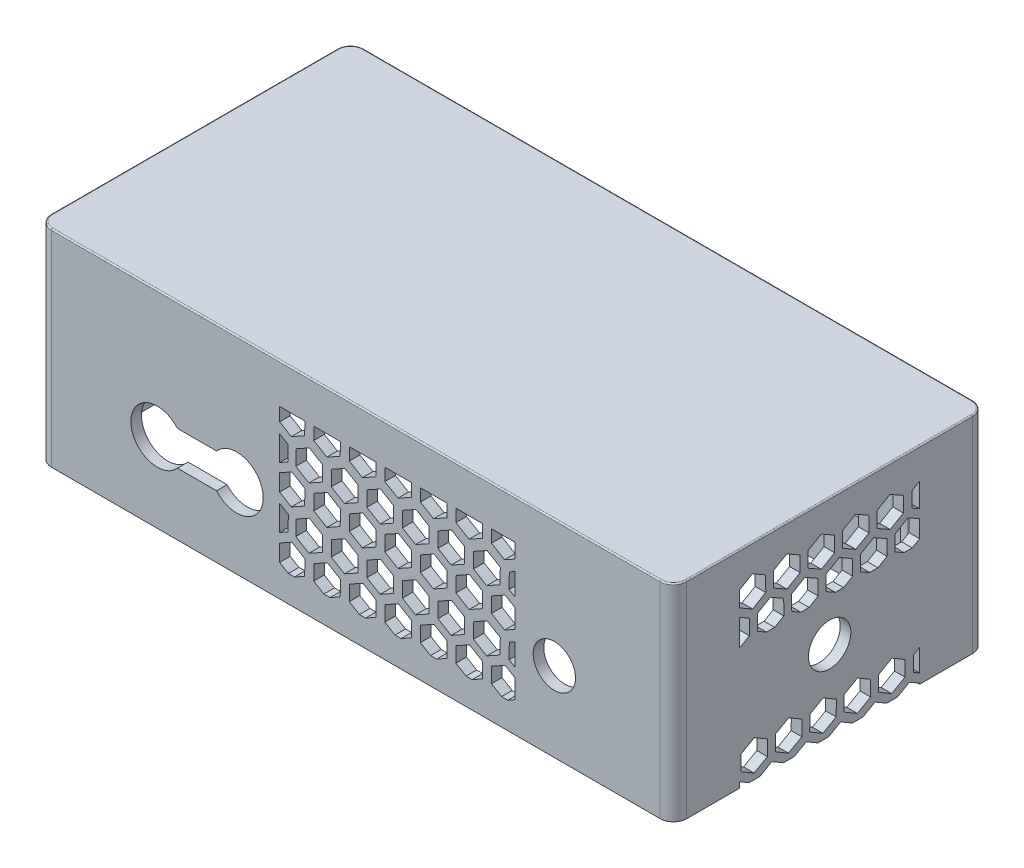
from build123d import *

# Parameters (mm, degrees)
SKETCH1_W                             = 240
SKETCH1_H                             = 118
BOSS_EXTRUDE1_DEPTH                   = 78
SKETCH2_W                             = 232
SKETCH2_H                             = 110
CUT_EXTRUDE1_DEPTH                    = 70
SKETCH3_W                             = 14
SKETCH3_H                             = 22
BOSS_EXTRUDE2_DEPTH                   = 77.2
FILLET1_R                             = 2
FILLET2_R                             = 6.5
FILLET3_R                             = 5
SKETCH4_R                             = 8
SIDE_LIDAR_AND_SONAR_HOLES_DEPTH      = 60
SIDE_LIDAR_AND_SONAR_HOLES_DEPTH_BACK = 60
SIDE_HONEYCOMB_DEPTH                  = 60
SIDE_HONEYCOMB_DEPTH_BACK             = 60
SKETCH6_R                             = 8
BACK_SONAR_DEPTH                      = 145
BACK_HONEYCOMB_DEPTH                  = 121
FILLET4_R                             = 0.5
FILLET6_R                             = 0.5


with BuildPart() as part:
    # Sketch1 → Boss-Extrude1 (new body)
    with BuildSketch(Plane(origin=(0, 0, 0), x_dir=(1, 0, 0), z_dir=(0, 1, 0))):
        Rectangle(SKETCH1_W, SKETCH1_H)
    extrude(amount=BOSS_EXTRUDE1_DEPTH)

    # Sketch2 → Cut-Extrude1 (cut)
    with BuildSketch(Plane(origin=(0, 0, 0), x_dir=(1, 0, 0), z_dir=(0, 1, 0))):
        Rectangle(SKETCH2_W, SKETCH2_H)
    extrude(amount=CUT_EXTRUDE1_DEPTH, mode=Mode.SUBTRACT)

    # Sketch3 → Boss-Extrude2 (add)
    with BuildSketch(Plane(origin=(0, 0, 0), x_dir=(1, 0, 0), z_dir=(0, 1, 0))):
        with Locations((-113, -48)):
            Rectangle(SKETCH3_W, SKETCH3_H)
        with Locations((-113, 48)):
            Rectangle(SKETCH3_W, SKETCH3_H)
        with Locations((113, -48)):
            Rectangle(SKETCH3_W, SKETCH3_H)
        with Locations((113, 48)):
            Rectangle(SKETCH3_W, SKETCH3_H)
    extrude(amount=BOSS_EXTRUDE2_DEPTH)

    # Fillet1
    fillet1_edges = [part.edges().sort_by_distance(p)[0] for p in [
        (-106, 35, 55),
        (-116, 35, 37),
        (-106, 35, -55),
        (-116, 35, -37),
        (116, 35, 37),
        (106, 35, 55),
        (116, 35, -37),
        (106, 35, -55),
    ]]
    fillet(fillet1_edges, radius=FILLET1_R)

    # Fillet2
    fillet2_edges = [part.edges().sort_by_distance(p)[0] for p in [
        (-106, 35, 37),
        (-106, 35, -37),
        (106, 35, 37),
        (106, 35, -37),
    ]]
    fillet(fillet2_edges, radius=FILLET2_R)

    # Fillet3
    fillet3_edges = [part.edges().sort_by_distance(p)[0] for p in [
        (-120, 39, -59),
        (120, 39, -59),
        (120, 39, 59),
        (-120, 39, 59),
    ]]
    fillet(fillet3_edges, radius=FILLET3_R)

    # Sketch4 → Side Lidar and Sonar holes (cut, two sides)
    with BuildSketch(Plane.XY) as side_lidar_and_sonar_holes_sk:
        with Locations((75, 30)):
            Circle(SKETCH4_R)
        with BuildLine():
            Line((-67.400657923, 23.5), (-52.599342077, 23.5))
            ThreePointArc((-52.599342077, 23.5), (-35, 30), (-52.599342077, 36.5))
            Line((-52.599342077, 36.5), (-67.400657923, 36.5))
            ThreePointArc((-67.400657923, 36.5), (-85, 30), (-67.400657923, 23.5))
        make_face()
    extrude(amount=SIDE_LIDAR_AND_SONAR_HOLES_DEPTH, mode=Mode.SUBTRACT)
    extrude(side_lidar_and_sonar_holes_sk.sketch, amount=-SIDE_LIDAR_AND_SONAR_HOLES_DEPTH_BACK, mode=Mode.SUBTRACT)

    # Sketch5 → Side honeycomb (cut, two sides)
    with BuildSketch(Plane.XY) as side_honeycomb_sk:
        Polygon((-19.337989227, 12.135440218), (-19.242729189, 17.908156984), (-24.194418539, 20.87701298), (-28.788182312, 18.324921994), (-28.788182312, 11.971607029), (-25.499782491, 10), (-23.18178162, 10), align=None)
        Polygon((-17.715816895, 20.490573702), (-12.668867508, 23.294434472), (-12.57360747, 29.067151238), (-17.552209114, 32.052142884), (-22.599158501, 29.248282113), (-22.694418539, 23.475565347), align=None)
        Polygon((-28.788182312, 41.324921994), (-28.788182312, 34.971607028), (-24.384938614, 32.331579448), (-19.337989227, 35.135440218), (-19.242729189, 40.908156984), (-24.194418539, 43.87701298), align=None)
        Polygon((-17.715816895, 43.490573702), (-12.668867508, 46.294434472), (-12.57360747, 52.067151238), (-17.552209114, 55.052142884), (-22.599158501, 52.248282113), (-22.694418539, 46.475565347), align=None)
        Polygon((-28.788182312, 63), (-28.788182312, 57.971607028), (-24.384938614, 55.331579448), (-19.337989227, 58.135440218), (-19.257715386, 63), align=None)
        Polygon((-5.827715386, 63), (-15.829076835, 63), (-15.906627963, 58.300435443), (-10.954938614, 55.331579448), (-5.907989227, 58.135440218), align=None)
        Polygon((7.602284614, 63), (-2.399076835, 63), (-2.476627963, 58.300435443), (2.475061386, 55.331579448), (7.522010773, 58.135440218), align=None)
        Polygon((-4.285816895, 43.490573702), (0.761132492, 46.294434472), (0.85639253, 52.067151238), (-4.122209114, 55.052142884), (-9.169158501, 52.248282113), (-9.264418539, 46.475565347), align=None)
        Polygon((2.475061386, 32.331579448), (7.522010773, 35.135440218), (7.617270811, 40.908156984), (2.665581461, 43.87701298), (-2.381367925, 41.073152209), (-2.476627963, 35.300435443), align=None)
        Polygon((-10.954938614, 32.331579448), (-5.907989227, 35.135440218), (-5.812729189, 40.908156984), (-10.764418539, 43.87701298), (-15.811367925, 41.073152209), (-15.906627963, 35.300435443), align=None)
        Polygon((-15.906627963, 12.300435443), (-12.069782491, 10), (-9.75178162, 10), (-5.907989227, 12.135440218), (-5.812729189, 17.908156984), (-10.764418539, 20.87701298), (-15.811367925, 18.073152209), align=None)
        Polygon((-2.476627963, 12.300435443), (1.360217509, 10), (3.67821838, 10), (7.522010773, 12.135440218), (7.617270811, 17.908156984), (2.665581461, 20.87701298), (-2.381367925, 18.073152209), align=None)
        Polygon((9.144183105, 20.490573702), (14.191132492, 23.294434472), (14.28639253, 29.067151238), (9.307790886, 32.052142884), (4.260841499, 29.248282113), (4.165581461, 23.475565347), align=None)
        Polygon((15.905061386, 32.331579448), (20.952010773, 35.135440218), (21.047270811, 40.908156984), (16.095581461, 43.87701298), (11.048632075, 41.073152209), (10.953372037, 35.300435443), align=None)
        Polygon((9.144183105, 43.490573702), (14.191132492, 46.294434472), (14.28639253, 52.067151238), (9.307790886, 55.052142884), (4.260841499, 52.248282113), (4.165581461, 46.475565347), align=None)
        Polygon((21.032284614, 63), (11.030923165, 63), (10.953372037, 58.300435443), (15.905061386, 55.331579448), (20.952010773, 58.135440218), align=None)
        Polygon((22.574183105, 43.490573702), (27.621132492, 46.294434472), (27.71639253, 52.067151238), (22.737790886, 55.052142884), (17.690841499, 52.248282113), (17.595581461, 46.475565347), align=None)
        Polygon((29.335061386, 32.331579448), (34.382010773, 35.135440218), (34.477270811, 40.908156984), (29.525581461, 43.87701298), (24.478632075, 41.073152209), (24.383372037, 35.300435443), align=None)
        Polygon((22.574183105, 20.490573702), (27.621132492, 23.294434472), (27.71639253, 29.067151238), (22.737790886, 32.052142884), (17.690841499, 29.248282113), (17.595581461, 23.475565347), align=None)
        Polygon((10.953372037, 12.300435443), (14.790217509, 10), (17.10821838, 10), (20.952010773, 12.135440218), (21.047270811, 17.908156984), (16.095581461, 20.87701298), (11.048632075, 18.073152209), align=None)
        Polygon((24.383372037, 12.300435443), (28.220217509, 10), (30.53821838, 10), (34.382010773, 12.135440218), (34.477270811, 17.908156984), (29.525581461, 20.87701298), (24.478632075, 18.073152209), align=None)
        Polygon((36.004183105, 20.490573702), (41.051132492, 23.294434472), (41.14639253, 29.067151238), (36.167790886, 32.052142884), (31.120841499, 29.248282113), (31.025581461, 23.475565347), align=None)
        Polygon((42.765061386, 32.331579448), (47.812010773, 35.135440218), (47.907270811, 40.908156984), (42.955581461, 43.87701298), (37.908632075, 41.073152209), (37.813372037, 35.300435443), align=None)
        Polygon((36.004183105, 43.490573702), (41.051132492, 46.294434472), (41.14639253, 52.067151238), (36.167790886, 55.052142884), (31.120841499, 52.248282113), (31.025581461, 46.475565347), align=None)
        Polygon((34.462284614, 63), (24.460923165, 63), (24.383372037, 58.300435443), (29.335061386, 55.331579448), (34.382010773, 58.135440218), align=None)
        Polygon((47.892284614, 63), (37.890923165, 63), (37.813372037, 58.300435443), (42.765061386, 55.331579448), (47.812010773, 58.135440218), align=None)
        Polygon((60.051433795, 63), (51.320923165, 63), (51.243372037, 58.300435443), (56.195061386, 55.331579448), (60.051433795, 57.474008564), align=None)
        Polygon((49.434183105, 43.490573702), (54.481132492, 46.294434472), (54.57639253, 52.067151238), (49.597790886, 55.052142884), (44.550841499, 52.248282113), (44.455581461, 46.475565347), align=None)
        Polygon((56.195061386, 32.331579448), (60.051433795, 34.474008564), (60.051433795, 41.679098912), (56.385581461, 43.87701298), (51.338632075, 41.073152209), (51.243372037, 35.300435443), align=None)
        Polygon((49.434183105, 20.490573702), (54.481132492, 23.294434472), (54.57639253, 29.067151238), (49.597790886, 32.052142884), (44.550841499, 29.248282113), (44.455581461, 23.475565347), align=None)
        Polygon((37.813372037, 12.300435443), (41.650217509, 10), (43.96821838, 10), (47.812010773, 12.135440218), (47.907270811, 17.908156984), (42.955581461, 20.87701298), (37.908632075, 18.073152209), align=None)
        Polygon((51.243372037, 12.300435443), (55.080217509, 10), (57.39821838, 10), (60.051433795, 11.474008564), (60.051433795, 18.679098912), (56.385581461, 20.87701298), (51.338632075, 18.073152209), align=None)
        Polygon((57.885581461, 23.475565347), (60.051433795, 22.17699768), (60.051433795, 30.398611166), (57.980841499, 29.248282113), align=None)
        Polygon((57.885581461, 46.475565347), (60.051433795, 45.17699768), (60.051433795, 53.398611166), (57.980841499, 52.248282113), align=None)
        Polygon((-28.788182312, 54.043770605), (-28.788182312, 44.656019005), (-25.708051359, 46.367202868), (-25.612791321, 52.139919633), align=None)
        Polygon((-28.788182312, 31.290347439), (-28.788182312, 21.777080674), (-25.599391493, 23.548631129), (-25.504131456, 29.321347894), align=None)
        Polygon((-9.169158501, 29.248282113), (-9.264418539, 23.475565347), (-4.285816895, 20.490573702), (0.761132492, 23.294434472), (0.85639253, 29.067151238), (-4.122209114, 32.052142884), align=None)
    extrude(amount=SIDE_HONEYCOMB_DEPTH, mode=Mode.SUBTRACT)
    extrude(side_honeycomb_sk.sketch, amount=-SIDE_HONEYCOMB_DEPTH_BACK, mode=Mode.SUBTRACT)

    # Sketch6 → Back Sonar (cut)
    with BuildSketch(Plane(origin=(0, 0, 0), x_dir=(0, 0, -1), z_dir=(1, 0, 0))):
        with Locations((0, 30)):
            Circle(SKETCH6_R)
    extrude(amount=BACK_SONAR_DEPTH, mode=Mode.SUBTRACT)

    # Sketch7 → Back Honeycomb (cut, through all)
    with BuildSketch(Plane(origin=(0, 0, 0), x_dir=(0, 0, -1), z_dir=(1, 0, 0))):
        Polygon((24.693001966, 47.965061299), (28.141421751, 46), (31.23665938, 46), (33.999999792, 47.616293449), (33.999999792, 54.171182077), (29.644009316, 56.653417082), (24.660393366, 53.738471904), align=None)
        Polygon((31.182214843, 59.044689386), (33.999999792, 57.433176236), (33.999999792, 66.474168555), (31.158592725, 64.818143874), align=None)
        Polygon((22.824808943, 67.725285503), (17.841192996, 64.810340327), (17.873800031, 59.036928806), (22.890024636, 56.178463348), (27.873640641, 59.093408559), (27.841033493, 64.866820077), align=None)
        Polygon((11.693002499, 47.965061299), (15.141422283, 46), (18.236659913, 46), (21.692844087, 48.021541687), (21.660235501, 53.794951028), (16.644009849, 56.653417082), (11.660393899, 53.738471904), align=None)
        Polygon((-1.306996968, 47.965061299), (2.141422816, 46), (5.236660446, 46), (8.692844222, 48.021541454), (8.660235631, 53.794951257), (3.644010382, 56.653417082), (-1.339605568, 53.738471904), align=None)
        Polygon((9.824809476, 67.725285503), (4.841193529, 64.810340327), (4.873800563, 59.036928806), (9.890025169, 56.178463348), (14.873641174, 59.093408559), (14.841034026, 64.866820077), align=None)
        Polygon((-3.175189991, 67.725285503), (-8.158805938, 64.810340327), (-8.126198904, 59.036928806), (-3.109974298, 56.178463348), (1.873641706, 59.093408559), (1.841034559, 64.866820077), align=None)
        Polygon((-14.306996435, 47.965061299), (-10.858576651, 46), (-7.763339021, 46), (-4.307155642, 48.021541222), (-4.339764238, 53.794951487), (-9.355989085, 56.653417082), (-14.339605035, 53.738471904), align=None)
        Polygon((-16.175189459, 67.725285503), (-21.158805405, 64.810340327), (-21.126198371, 59.036928806), (-16.109973765, 56.178463348), (-11.126357761, 59.093408559), (-11.158964908, 64.866820077), align=None)
        Polygon((-24.158964375, 64.866820077), (-29.175188926, 67.725285503), (-34, 64.903226196), (-34, 58.965015727), (-29.109973232, 56.178463348), (-24.126357228, 59.093408559), align=None)
        Polygon((-27.306995902, 47.965061299), (-23.858576118, 46), (-20.763338489, 46), (-17.307155506, 48.02154099), (-17.339764107, 53.794951716), (-22.355988552, 56.653417082), (-27.339604502, 53.738471904), align=None)
        Polygon((-30.339763977, 53.794951945), (-34, 55.880715455), (-34, 46), (-33.763337956, 46), (-30.30715537, 48.021540758), align=None)
        Polygon((-34, 0), (-30.417938998, 0), (-34, 2.102331682), align=None)
        Polygon((-26.368714304, 0), (-17.417938998, 0), (-21.819566478, 2.583339842), align=None)
        Polygon((-13.368714304, 0), (-4.417938998, 0), (-8.819566478, 2.583339842), align=None)
        Polygon((-10.47499741, 10.843195674), (-15.454267934, 13.765557456), (-20.474742738, 10.914563581), (-20.515947018, 5.141207924), (-15.536676495, 2.218846142), (-10.516201691, 5.069840017), align=None)
        Polygon((-23.47499741, 10.843195674), (-28.454267934, 13.765557456), (-33.474742738, 10.914563581), (-33.515947018, 5.141207924), (-28.536676495, 2.218846142), (-23.516201691, 5.069840017), align=None)
        Polygon((2.52500259, 10.843195674), (-2.454267934, 13.765557456), (-7.474742738, 10.914563581), (-7.515947018, 5.141207924), (-2.536676495, 2.218846142), (2.483798309, 5.069840017), align=None)
        Polygon((34, 3.673167369), (34, 12.090180683), (31.731622482, 10.80202953), (31.690418201, 5.028673873), align=None)
        Polygon((28.52500259, 10.843195674), (23.545732066, 13.765557456), (18.525257262, 10.914563581), (18.484052982, 5.141207924), (23.463323505, 2.218846142), (28.483798309, 5.069840017), align=None)
        Polygon((25.631285696, 0), (34, 0), (34, 0.341614865), (30.180433522, 2.583339842), align=None)
        Polygon((12.631285696, 0), (21.582061002, 0), (17.180433522, 2.583339842), align=None)
        Polygon((-0.368714304, 0), (8.582061002, 0), (4.180433522, 2.583339842), align=None)
        Polygon((15.52500259, 10.843195674), (10.545732066, 13.765557456), (5.525257262, 10.914563581), (5.484052982, 5.141207924), (10.463323505, 2.218846142), (15.483798309, 5.069840017), align=None)
    extrude(amount=BACK_HONEYCOMB_DEPTH, mode=Mode.SUBTRACT)

    # Fillet4
    fillet4_edges = [part.edges().sort_by_distance(p)[0] for p in [
        (120, 78, 0),
        (0, 78, 59),
        (-120, 78, 0),
        (0, 78, -59),
        (-118.535533906, 78, 57.535533906),
        (-118.535533906, 78, -57.535533906),
        (118.535533906, 78, -57.535533906),
        (118.535533906, 78, 57.535533906),
    ]]
    fillet(fillet4_edges, radius=FILLET4_R)

    # Fillet6
    fillet6_edges = [part.edges().sort_by_distance(p)[0] for p in [
        (0, 70, -55),
        (106, 70, -48.25),
        (116, 70, 0),
        (113.25, 70, 37),
        (0, 70, 55),
        (-106, 70, 48.25),
        (-116, 70, 0),
        (-113.25, 70, -37),
        (-115.414213562, 70, 36.414213562),
        (-105.414213562, 70, 54.414213562),
        (-115.414213562, 70, -36.414213562),
        (-105.414213562, 70, -54.414213562),
        (105.414213562, 70, 54.414213562),
        (115.414213562, 70, 36.414213562),
        (115.414213562, 70, -36.414213562),
        (105.414213562, 70, -54.414213562),
        (113.25, 70, -37),
        (106, 70, 48.25),
        (-106, 70, -48.25),
        (-113.25, 70, 37),
        (107.903805922, 70, -38.903805922),
        (107.903805922, 70, 38.903805922),
        (-107.903805922, 70, -38.903805922),
        (-107.903805922, 70, 38.903805922),
    ]]
    fillet(fillet6_edges, radius=FILLET6_R)


solid = part.part
